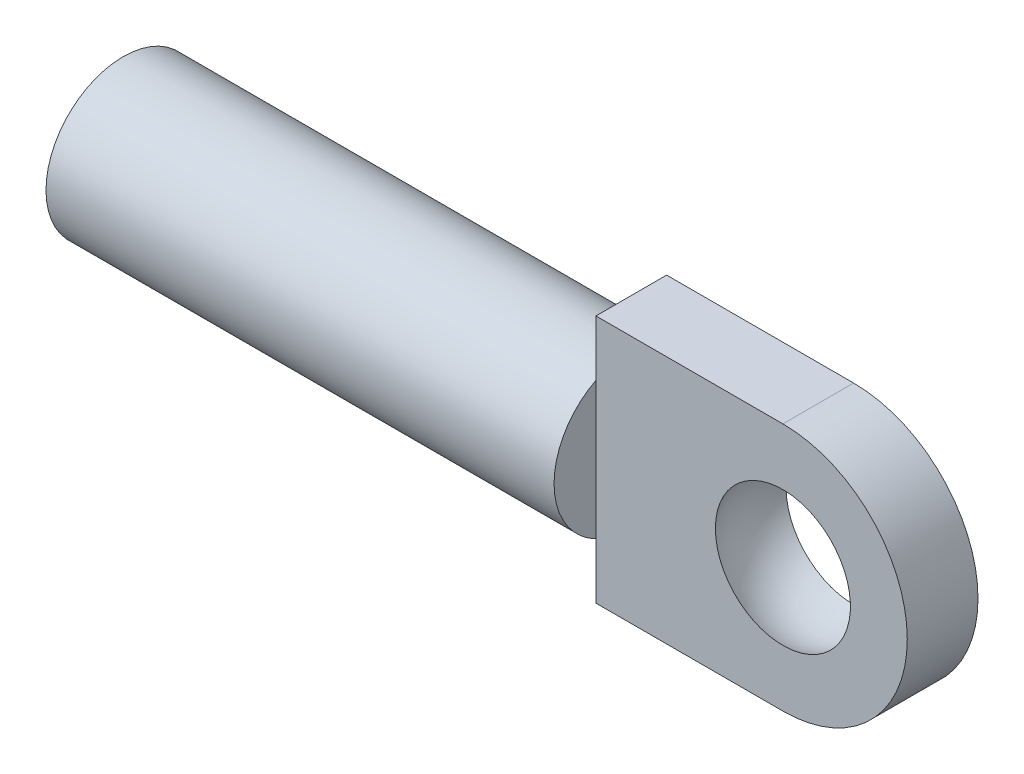
from build123d import *

# Parameters (mm, degrees)
EXTRUDE1_DEPTH      = 1.1049
EXTRUDE1_DEPTH_BACK = 1.1049
SKETCH2_R           = 2.413
EXTRUDE2_DEPTH      = 15.875
SKETCH3_R           = 1.2065
EXTRUDE3_DEPTH      = 14.859


with BuildPart() as part:
    # Sketch1 → Extrude1 (new body, two sides)
    with BuildSketch(Plane.XY) as extrude1_sk:
        with BuildLine():
            Line((0, 3.8862), (-5.842, 3.8862))
            Line((-5.842, 3.8862), (-5.842, -3.8862))
            Line((-5.842, -3.8862), (0, -3.8862))
            ThreePointArc((0, -3.8862), (3.8862, 0), (0, 3.8862))
        make_face()
    extrude(amount=EXTRUDE1_DEPTH)
    extrude(extrude1_sk.sketch, amount=-EXTRUDE1_DEPTH_BACK)

    # Sketch2 → Extrude2 (add)
    with BuildSketch(Plane.ZY.offset(5.842)):
        Circle(SKETCH2_R)
    extrude(amount=EXTRUDE2_DEPTH)

    # Sketch3 → Extrude3 (cut)
    with BuildSketch(Plane.ZY.offset(21.717)):
        Circle(SKETCH3_R)
    extrude(amount=-EXTRUDE3_DEPTH, mode=Mode.SUBTRACT)

    # Sketch6 → Cut-Revolve1 (revolve, cut)
    with BuildSketch(Plane.XY):
        with BuildLine():
            Line((0, -2.38125), (0, 2.38125))
            ThreePointArc((0, 2.38125), (-2.38125, 0), (0, -2.38125))
        make_face()
    revolve(axis=Axis((0, -2.38125, 0), (0, 1, 0)), mode=Mode.SUBTRACT)


solid = part.part
